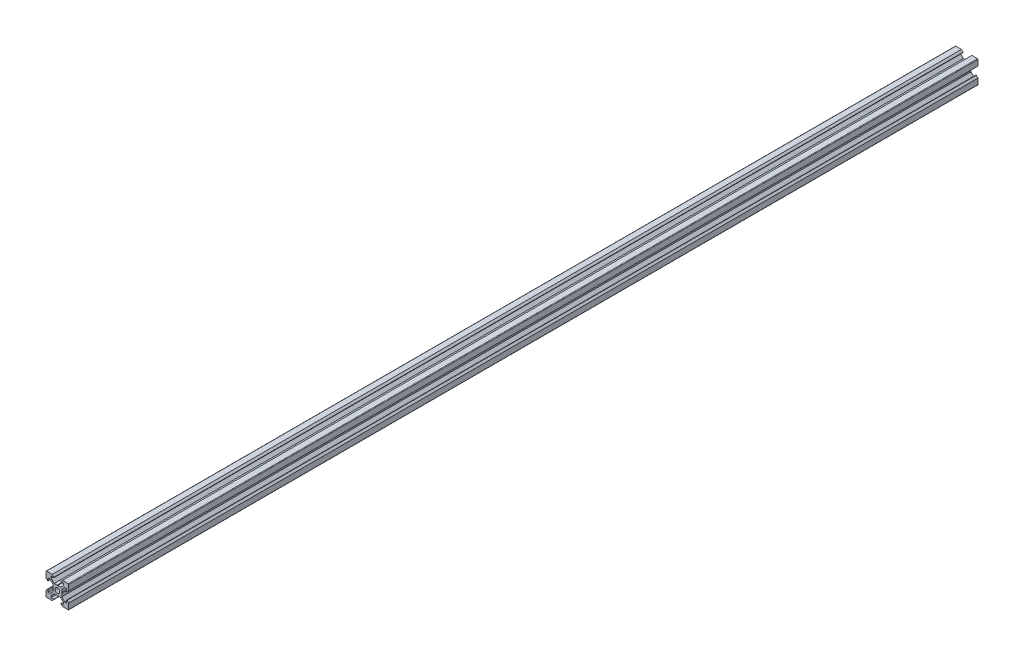
from build123d import *

# Parameters (mm, degrees)
SKETCH1_R           = 2.1
BOSS_EXTRUDE1_DEPTH = 800


with BuildPart() as part:
    # Sketch1 → Boss-Extrude1 (new body)
    with BuildSketch(Plane.XY):
        with BuildLine():
            Line((3.69, 0), (3.9, -0.21))
            Line((3.9, -0.21), (3.9, -2.839339828))
            Line((3.9, -2.839339828), (6.560660172, -5.5))
            Line((6.560660172, -5.5), (8.2, -5.5))
            Line((8.2, -5.5), (8.2, -3.125))
            Line((8.2, -3.125), (8.545, -3.125))
            Line((8.545, -3.125), (10, -4.58))
            Line((10, -4.58), (10, -9.5))
            ThreePointArc((10, -9.5), (9.853553391, -9.853553391), (9.5, -10))
            Line((9.5, -10), (4.58, -10))
            Line((4.58, -10), (3.125, -8.545))
            Line((3.125, -8.545), (3.125, -8.2))
            Line((3.125, -8.2), (5.5, -8.2))
            Line((5.5, -8.2), (5.5, -6.560660172))
            Line((5.5, -6.560660172), (2.839339828, -3.9))
            Line((2.839339828, -3.9), (0.21, -3.9))
            Line((0.21, -3.9), (0, -3.69))
            Line((0, -3.69), (-0.21, -3.9))
            Line((-0.21, -3.9), (-2.839339828, -3.9))
            Line((-2.839339828, -3.9), (-5.5, -6.560660172))
            Line((-5.5, -6.560660172), (-5.5, -8.2))
            Line((-5.5, -8.2), (-3.125, -8.2))
            Line((-3.125, -8.2), (-3.125, -8.545))
            Line((-3.125, -8.545), (-4.58, -10))
            Line((-4.58, -10), (-9.5, -10))
            ThreePointArc((-9.5, -10), (-9.853553391, -9.853553391), (-10, -9.5))
            Line((-10, -9.5), (-10, -4.58))
            Line((-10, -4.58), (-8.545, -3.125))
            Line((-8.545, -3.125), (-8.2, -3.125))
            Line((-8.2, -3.125), (-8.2, -5.5))
            Line((-8.2, -5.5), (-6.560660172, -5.5))
            Line((-6.560660172, -5.5), (-3.9, -2.839339828))
            Line((-3.9, -2.839339828), (-3.9, -0.21))
            Line((-3.9, -0.21), (-3.69, 0))
            Line((-3.69, 0), (-3.9, 0.21))
            Line((-3.9, 0.21), (-3.9, 2.839339828))
            Line((-3.9, 2.839339828), (-6.560660172, 5.5))
            Line((-6.560660172, 5.5), (-8.2, 5.5))
            Line((-8.2, 5.5), (-8.2, 3.125))
            Line((-8.2, 3.125), (-8.545, 3.125))
            Line((-8.545, 3.125), (-10, 4.58))
            Line((-10, 4.58), (-10, 9.5))
            ThreePointArc((-10, 9.5), (-9.853553391, 9.853553391), (-9.5, 10))
            Line((-9.5, 10), (-4.58, 10))
            Line((-4.58, 10), (-3.125, 8.545))
            Line((-3.125, 8.545), (-3.125, 8.2))
            Line((-3.125, 8.2), (-5.5, 8.2))
            Line((-5.5, 8.2), (-5.5, 6.560660172))
            Line((-5.5, 6.560660172), (-2.839339828, 3.9))
            Line((-2.839339828, 3.9), (-0.21, 3.9))
            Line((-0.21, 3.9), (0, 3.69))
            Line((0, 3.69), (0.21, 3.9))
            Line((0.21, 3.9), (2.839339828, 3.9))
            Line((2.839339828, 3.9), (5.5, 6.560660172))
            Line((5.5, 6.560660172), (5.5, 8.2))
            Line((5.5, 8.2), (3.125, 8.2))
            Line((3.125, 8.2), (3.125, 8.545))
            Line((3.125, 8.545), (4.58, 10))
            Line((4.58, 10), (9.5, 10))
            ThreePointArc((9.5, 10), (9.853553391, 9.853553391), (10, 9.5))
            Line((10, 9.5), (10, 4.58))
            Line((10, 4.58), (8.545, 3.125))
            Line((8.545, 3.125), (8.2, 3.125))
            Line((8.2, 3.125), (8.2, 5.5))
            Line((8.2, 5.5), (6.560660172, 5.5))
            Line((6.560660172, 5.5), (3.9, 2.839339828))
            Line((3.9, 2.839339828), (3.9, 0.21))
            Line((3.9, 0.21), (3.69, 0))
        make_face()
        Circle(SKETCH1_R, mode=Mode.SUBTRACT)
    extrude(amount=BOSS_EXTRUDE1_DEPTH)


solid = part.part
